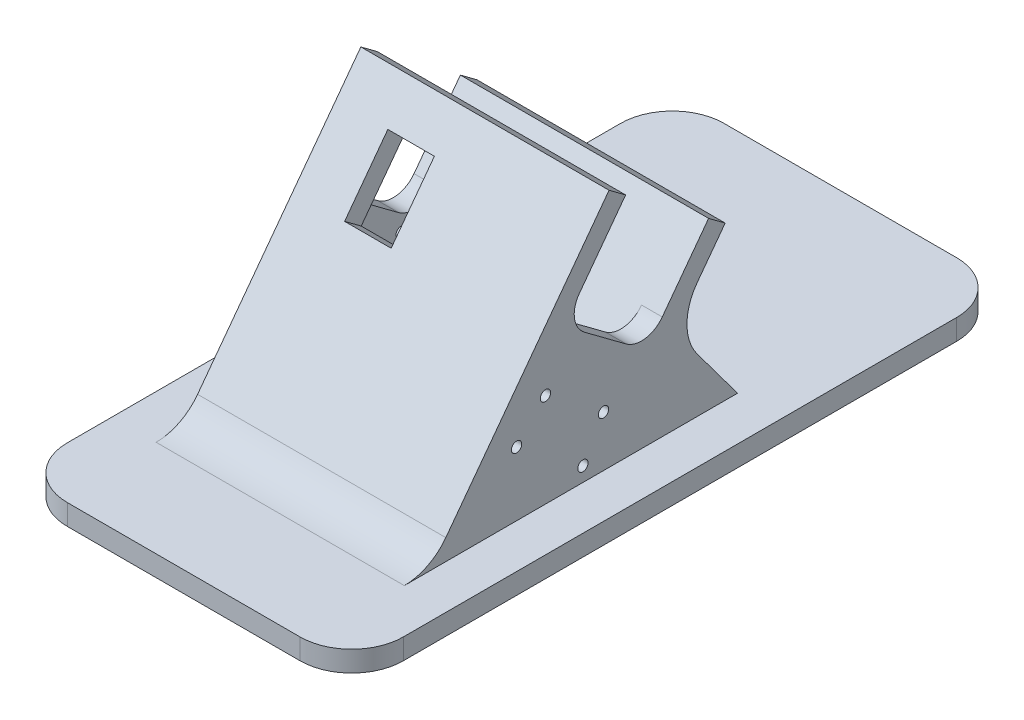
from build123d import *

# Parameters (mm, degrees)
BASE_PLATE_EXTRUDE_DEPTH    = 4
MOTORCASEEXTRUDE_DEPTH      = 24
MOTORCASEEXTRUDE_DEPTH_BACK = 24
SKETCH7_W                   = 40
SKETCH7_H                   = 20
CUT_EXTRUDE1_DEPTH          = 44
SKETCH9_W                   = 48
SKETCH9_H                   = 4
CUT_EXTRUDE2_DEPTH          = 28
FILLET_2_DEPTH              = 48
SKETCH11_W                  = 9
SKETCH11_H                  = 14
HOLE_FOR_WIRE_DEPTH         = 4
CUT_EXTRUDE3_REACH          = 14.5
SKETCH13_R                  = 1
CUT_EXTRUDE4_REACH          = 14.5
SKETCH14_R                  = 1


with BuildPart() as part:
    # Sketch1 → base_plate_extrude (new body)
    with BuildSketch(Plane(origin=(0, 0, 0), x_dir=(1, 0, 0), z_dir=(0, 1, 0))):
        with BuildLine():
            Line((-22.5, -63.5), (22.5, -63.5))
            ThreePointArc((22.5, -63.5), (29.571067812, -60.571067812), (32.5, -53.5))
            Line((32.5, -53.5), (32.5, 53.5))
            ThreePointArc((32.5, 53.5), (29.571067812, 60.571067812), (22.5, 63.5))
            Line((22.5, 63.5), (-22.5, 63.5))
            ThreePointArc((-22.5, 63.5), (-29.571067812, 60.571067812), (-32.5, 53.5))
            Line((-32.5, 53.5), (-32.5, -53.5))
            ThreePointArc((-32.5, -53.5), (-29.571067812, -60.571067812), (-22.5, -63.5))
        make_face()
    extrude(amount=BASE_PLATE_EXTRUDE_DEPTH)

    # Sketch5 → MotorCaseExtrude (add, two sides)
    with BuildSketch(Plane.ZY) as motorcaseextrude_sk:
        with BuildLine():
            Line((31.511856475, 15.127443917), (2.840895128, 53.623884992))
            Line((2.840895128, 53.623884992), (-19.615362165, 36.89915754))
            Line((-19.615362165, 36.89915754), (-11.812816694, 26.422695717))
            ThreePointArc((-11.812816694, 26.422695717), (-9.832908585, 20.44957877), (-11.812816694, 14.476461823))
            Line((-11.812816694, 14.476461823), (-19.615362165, 4))
            Line((-19.615362165, 4), (39.799233322, 4))
            Line((39.799233322, 4), (44.820226981, 4))
            ThreePointArc((44.820226981, 4), (40.333088108, 5.063245291), (36.80013509, 8.026883053))
            Line((36.80013509, 8.026883053), (31.511856475, 15.127443917))
        make_face()
    extrude(amount=MOTORCASEEXTRUDE_DEPTH)
    extrude(motorcaseextrude_sk.sketch, amount=-MOTORCASEEXTRUDE_DEPTH_BACK)

    # Sketch7 → Cut-Extrude1 (cut)
    with BuildSketch(Plane(origin=(0, 33.130958404, -24.674915427), x_dir=(1, 0, 0), z_dir=(0, 0.802009189, -0.597311695))):
        with Locations((0, -20.308597621)):
            Rectangle(SKETCH7_W, SKETCH7_H)
    extrude(amount=-CUT_EXTRUDE1_DEPTH, mode=Mode.SUBTRACT)

    # Sketch9 → Cut-Extrude2 (cut)
    with BuildSketch(Plane(origin=(0, 20.492926589, 27.515810556), x_dir=(1, 0, 0), z_dir=(0, 0.597311695, 0.802009189))):
        with Locations((0, 39.309948633)):
            Rectangle(SKETCH9_W, SKETCH9_H)
    extrude(amount=-CUT_EXTRUDE2_DEPTH, mode=Mode.SUBTRACT)

    # Sketch10 → fillet 2 (cut)
    with BuildSketch(Plane.ZY.offset(24)):
        with BuildLine():
            Line((-14.01807863, 36.080367563), (2.022105151, 48.026601457))
            Line((2.022105151, 48.026601457), (10.981780572, 35.996463621))
            ThreePointArc((10.981780572, 35.996463621), (11.919081057, 32.286190216), (9.9582931, 28.999859202))
            Line((9.9582931, 28.999859202), (1.93820121, 23.026742255))
            ThreePointArc((1.93820121, 23.026742255), (-1.772072196, 22.08944177), (-5.058403209, 24.050229727))
            Line((-5.058403209, 24.050229727), (-14.01807863, 36.080367563))
        make_face()
    extrude(amount=-FILLET_2_DEPTH, mode=Mode.SUBTRACT)

    # Sketch11 → Hole for wire (cut)
    with BuildSketch(Plane(origin=(0, 20.492926589, 27.515810556), x_dir=(1, 0, 0), z_dir=(0, 0.597311695, 0.802009189))):
        with Locations((-9.5, 22.309948633)):
            Rectangle(SKETCH11_W, SKETCH11_H)
    extrude(amount=-HOLE_FOR_WIRE_DEPTH, mode=Mode.SUBTRACT)

    # Sketch13 → Cut-Extrude3 (cut, up to next)
    with BuildSketch(Plane(origin=(-20, 0, 0), x_dir=(0, 0, -1), z_dir=(1, 0, 0)), mode=Mode.PRIVATE) as cut_extrude3_sk1:
        with Locations((-6.306750122, 13.811617607)):
            Circle(SKETCH13_R)
    cut_extrude3_tool1 = extrude(cut_extrude3_sk1.sketch, amount=-CUT_EXTRUDE3_REACH, mode=Mode.PRIVATE) & part.part
    add(cut_extrude3_tool1.solids().sort_by_distance((-20, 13.811618, 6.30675))[0], mode=Mode.SUBTRACT)
    # Sketch13 → Cut-Extrude3 (cut, up to next)
    with BuildSketch(Plane(origin=(-20, 0, 0), x_dir=(0, 0, -1), z_dir=(1, 0, 0)), mode=Mode.PRIVATE) as cut_extrude3_sk2:
        with Locations((-1.425907817, 19.528030678)):
            Circle(SKETCH13_R)
    cut_extrude3_tool2 = extrude(cut_extrude3_sk2.sketch, amount=-CUT_EXTRUDE3_REACH, mode=Mode.PRIVATE) & part.part
    add(cut_extrude3_tool2.solids().sort_by_distance((-20, 19.528031, 1.425908))[0], mode=Mode.SUBTRACT)
    # Sketch13 → Cut-Extrude3 (cut, up to next)
    with BuildSketch(Plane(origin=(-20, 0, 0), x_dir=(0, 0, -1), z_dir=(1, 0, 0)), mode=Mode.PRIVATE) as cut_extrude3_sk3:
        with Locations((-13.456045653, 28.487706099)):
            Circle(SKETCH13_R)
    cut_extrude3_tool3 = extrude(cut_extrude3_sk3.sketch, amount=-CUT_EXTRUDE3_REACH, mode=Mode.PRIVATE) & part.part
    add(cut_extrude3_tool3.solids().sort_by_distance((-20, 28.487706, 13.456046))[0], mode=Mode.SUBTRACT)
    # Sketch13 → Cut-Extrude3 (cut, up to next)
    with BuildSketch(Plane(origin=(-20, 0, 0), x_dir=(0, 0, -1), z_dir=(1, 0, 0)), mode=Mode.PRIVATE) as cut_extrude3_sk4:
        with Locations((-17.534878769, 22.173981333)):
            Circle(SKETCH13_R)
    cut_extrude3_tool4 = extrude(cut_extrude3_sk4.sketch, amount=-CUT_EXTRUDE3_REACH, mode=Mode.PRIVATE) & part.part
    add(cut_extrude3_tool4.solids().sort_by_distance((-20, 22.173981, 17.534879))[0], mode=Mode.SUBTRACT)

    # Sketch14 → Cut-Extrude4 (cut, up to next)
    with BuildSketch(Plane.ZY.offset(-20), mode=Mode.PRIVATE) as cut_extrude4_sk1:
        with Locations((10.283784148, 6.798641768)):
            Circle(SKETCH14_R)
    cut_extrude4_tool1 = extrude(cut_extrude4_sk1.sketch, amount=-CUT_EXTRUDE4_REACH, mode=Mode.PRIVATE) & part.part
    add(cut_extrude4_tool1.solids().sort_by_distance((20, 6.798642, 10.283784))[0], mode=Mode.SUBTRACT)
    # Sketch14 → Cut-Extrude4 (cut, up to next)
    with BuildSketch(Plane.ZY.offset(-20), mode=Mode.PRIVATE) as cut_extrude4_sk2:
        with Locations((23.115931173, 16.355628883)):
            Circle(SKETCH14_R)
    cut_extrude4_tool2 = extrude(cut_extrude4_sk2.sketch, amount=-CUT_EXTRUDE4_REACH, mode=Mode.PRIVATE) & part.part
    add(cut_extrude4_tool2.solids().sort_by_distance((20, 16.355629, 23.115931))[0], mode=Mode.SUBTRACT)
    # Sketch14 → Cut-Extrude4 (cut, up to next)
    with BuildSketch(Plane.ZY.offset(-20), mode=Mode.PRIVATE) as cut_extrude4_sk3:
        with Locations((6.307299779, 13.812026975)):
            Circle(SKETCH14_R)
    cut_extrude4_tool3 = extrude(cut_extrude4_sk3.sketch, amount=-CUT_EXTRUDE4_REACH, mode=Mode.PRIVATE) & part.part
    add(cut_extrude4_tool3.solids().sort_by_distance((20, 13.812027, 6.3073))[0], mode=Mode.SUBTRACT)
    # Sketch14 → Cut-Extrude4 (cut, up to next)
    with BuildSketch(Plane.ZY.offset(-20), mode=Mode.PRIVATE) as cut_extrude4_sk4:
        with Locations((17.535428426, 22.174390701)):
            Circle(SKETCH14_R)
    cut_extrude4_tool4 = extrude(cut_extrude4_sk4.sketch, amount=-CUT_EXTRUDE4_REACH, mode=Mode.PRIVATE) & part.part
    add(cut_extrude4_tool4.solids().sort_by_distance((20, 22.174391, 17.535428))[0], mode=Mode.SUBTRACT)


solid = part.part
